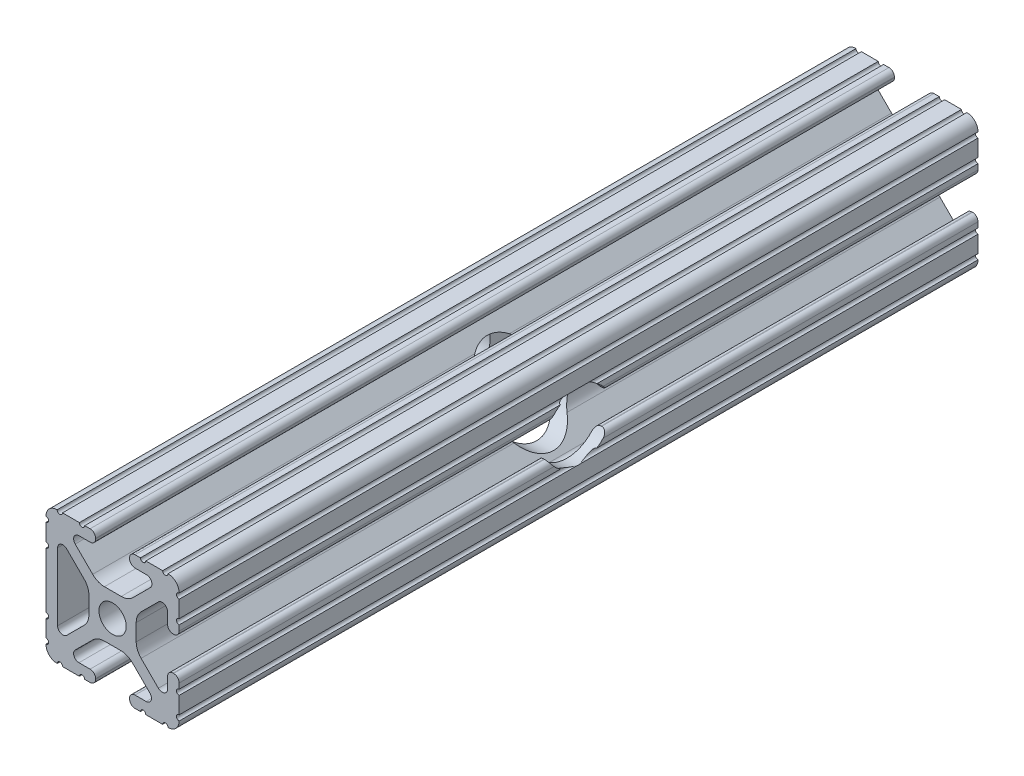
from build123d import *

# Parameters (mm, degrees)
SKETCH1_R           = 2.6035
BOSS_EXTRUDE1_DEPTH = 152.4
SKETCH2_R           = 6.35
CUT_EXTRUDE1_DEPTH  = 26.4


with BuildPart() as part:
    # Sketch1 → Boss-Extrude1 (new body)
    with BuildSketch(Plane(origin=(0, 0, -152.4), x_dir=(-1, 0, 0), z_dir=(0, 0, -1))):
        with BuildLine():
            Line((6.416409763, -10.4902), (4.28752, -10.4902))
            ThreePointArc((4.28752, -10.4902), (3.545750844, -10.797450844), (3.2385, -11.53922))
            Line((3.2385, -11.53922), (3.2385, -11.65098))
            ThreePointArc((3.2385, -11.65098), (3.545750844, -12.392749156), (4.28752, -12.7))
            Line((4.28752, -12.7), (5.3170836, -12.7))
            ThreePointArc((5.3170836, -12.7), (5.8250836, -12.192), (6.3330836, -12.7))
            Line((6.3330836, -12.7), (9.5504, -12.7))
            ThreePointArc((9.5504, -12.7), (10.058323491, -12.192000006), (10.566399977, -12.699846982))
            ThreePointArc((10.566399977, -12.699846982), (12.082522516, -12.082522516), (12.699846982, -10.566399977))
            ThreePointArc((12.699846982, -10.566399977), (12.192000006, -10.058323491), (12.7, -9.5504))
            Line((12.7, -9.5504), (12.7, -6.3330836))
            ThreePointArc((12.7, -6.3330836), (12.192, -5.8250836), (12.7, -5.3170836))
            Line((12.7, -5.3170836), (12.7, 5.3171344))
            ThreePointArc((12.7, 5.3171344), (12.192, 5.8251344), (12.7, 6.3331344))
            Line((12.7, 6.3331344), (12.7, 9.5504))
            ThreePointArc((12.7, 9.5504), (12.192000006, 10.058323491), (12.699846982, 10.566399977))
            ThreePointArc((12.699846982, 10.566399977), (12.082522516, 12.082522516), (10.566399977, 12.699846982))
            ThreePointArc((10.566399977, 12.699846982), (10.058323491, 12.192000006), (9.5504, 12.7))
            Line((9.5504, 12.7), (6.3331344, 12.7))
            ThreePointArc((6.3331344, 12.7), (5.8251344, 12.192), (5.3171344, 12.7))
            Line((5.3171344, 12.7), (4.2874692, 12.7))
            ThreePointArc((4.2874692, 12.7), (3.545700044, 12.392749156), (3.2384492, 11.65098))
            Line((3.2384492, 11.65098), (3.2384492, 11.53922))
            ThreePointArc((3.2384492, 11.53922), (3.545700044, 10.797450844), (4.2874692, 10.4902))
            Line((4.2874692, 10.4902), (6.416384363, 10.4902))
            ThreePointArc((6.416384363, 10.4902), (7.355223148, 9.862578342), (7.134149423, 8.755124678))
            Line((7.134149423, 8.755124678), (3.796632915, 5.423689619))
            ThreePointArc((3.796632915, 5.423689619), (2.767299421, 4.736928798), (1.553617102, 4.4958))
            Line((1.553617102, 4.4958), (-1.657299581, 4.4958))
            ThreePointArc((-1.657299581, 4.4958), (-2.8709819, 4.736928798), (-3.900315394, 5.423689619))
            Line((-3.900315394, 5.423689619), (-7.207191475, 8.724540082))
            ThreePointArc((-7.207191475, 8.724540082), (-7.43216212, 9.851515102), (-6.476774195, 10.4902))
            Line((-6.476774195, 10.4902), (-4.2874692, 10.4902))
            ThreePointArc((-4.2874692, 10.4902), (-3.545700044, 10.797450844), (-3.2384492, 11.53922))
            Line((-3.2384492, 11.53922), (-3.2384492, 11.65098))
            ThreePointArc((-3.2384492, 11.65098), (-3.545700044, 12.392749156), (-4.2874692, 12.7))
            Line((-4.2874692, 12.7), (-5.3170836, 12.7))
            ThreePointArc((-5.3170836, 12.7), (-5.8250836, 12.192), (-6.3330836, 12.7))
            Line((-6.3330836, 12.7), (-9.5504, 12.7))
            ThreePointArc((-9.5504, 12.7), (-10.058323491, 12.192000006), (-10.566399977, 12.699846982))
            ThreePointArc((-10.566399977, 12.699846982), (-12.082522516, 12.082522516), (-12.699846982, 10.566399977))
            ThreePointArc((-12.699846982, 10.566399977), (-12.192000006, 10.058323491), (-12.7, 9.5504))
            Line((-12.7, 9.5504), (-12.7, 6.3331344))
            ThreePointArc((-12.7, 6.3331344), (-12.192, 5.8251344), (-12.7, 5.3171344))
            Line((-12.7, 5.3171344), (-12.7, 4.287470133))
            ThreePointArc((-12.7, 4.287470133), (-12.392749156, 3.545700977), (-11.65098, 3.238450133))
            Line((-11.65098, 3.238450133), (-11.53922, 3.238450133))
            ThreePointArc((-11.53922, 3.238450133), (-10.797450844, 3.545700977), (-10.4902, 4.287470133))
            Line((-10.4902, 4.287470133), (-10.4902, 6.402089023))
            ThreePointArc((-10.4902, 6.402089023), (-9.856394933, 7.351113629), (-8.736962546, 7.129240479))
            Line((-8.736962546, 7.129240479), (-5.440484187, 3.838768792))
            ThreePointArc((-5.440484187, 3.838768792), (-4.75073678, 2.808015636), (-4.5085, 1.591658411))
            Line((-4.5085, 1.591658411), (-4.5085, -1.591658411))
            ThreePointArc((-4.5085, -1.591658411), (-4.75073678, -2.808015636), (-5.440484187, -3.838768792))
            Line((-5.440484187, -3.838768792), (-8.736962546, -7.129240479))
            ThreePointArc((-8.736962546, -7.129240479), (-9.856394933, -7.351113629), (-10.4902, -6.402089023))
            Line((-10.4902, -6.402089023), (-10.4902, -4.287470133))
            ThreePointArc((-10.4902, -4.287470133), (-10.797450844, -3.545700977), (-11.53922, -3.238450133))
            Line((-11.53922, -3.238450133), (-11.65098, -3.238450133))
            ThreePointArc((-11.65098, -3.238450133), (-12.392749156, -3.545700977), (-12.7, -4.287470133))
            Line((-12.7, -4.287470133), (-12.7, -5.3170836))
            ThreePointArc((-12.7, -5.3170836), (-12.192, -5.8250836), (-12.7, -6.3330836))
            Line((-12.7, -6.3330836), (-12.7, -9.5504))
            ThreePointArc((-12.7, -9.5504), (-12.192000006, -10.058323491), (-12.699846982, -10.566399977))
            ThreePointArc((-12.699846982, -10.566399977), (-12.082522516, -12.082522516), (-10.566399977, -12.699846982))
            ThreePointArc((-10.566399977, -12.699846982), (-10.058323491, -12.192000006), (-9.5504, -12.7))
            Line((-9.5504, -12.7), (-6.3331344, -12.7))
            ThreePointArc((-6.3331344, -12.7), (-5.8251344, -12.192), (-5.3171344, -12.7))
            Line((-5.3171344, -12.7), (-4.28752, -12.7))
            ThreePointArc((-4.28752, -12.7), (-3.545750844, -12.392749156), (-3.2385, -11.65098))
            Line((-3.2385, -11.65098), (-3.2385, -11.53922))
            ThreePointArc((-3.2385, -11.53922), (-3.545750844, -10.797450844), (-4.28752, -10.4902))
            Line((-4.28752, -10.4902), (-6.40834956, -10.4902))
            ThreePointArc((-6.40834956, -10.4902), (-7.350269456, -9.860518594), (-7.128470204, -8.749430454))
            Line((-7.128470204, -8.749430454), (-3.796658315, -5.423689619))
            ThreePointArc((-3.796658315, -5.423689619), (-2.767324821, -4.736928798), (-1.553642502, -4.4958))
            Line((-1.553642502, -4.4958), (1.553642502, -4.4958))
            ThreePointArc((1.553642502, -4.4958), (2.767324821, -4.736928798), (3.796658315, -5.423689619))
            Line((3.796658315, -5.423689619), (7.134174823, -8.755124678))
            ThreePointArc((7.134174823, -8.755124678), (7.355248548, -9.862578342), (6.416409763, -10.4902))
        make_face()
        Circle(SKETCH1_R, mode=Mode.SUBTRACT)
        with BuildLine():
            Line((10.4902, 6.446436794), (10.4902, -6.425372487))
            ThreePointArc((10.4902, -6.425372487), (9.862352148, -7.36547709), (8.753441447, -7.145689354))
            Line((8.753441447, -7.145689354), (5.440484187, -3.838768792))
            ThreePointArc((5.440484187, -3.838768792), (4.75073678, -2.808015636), (4.5085, -1.591658411))
            Line((4.5085, -1.591658411), (4.5085, 1.591658411))
            ThreePointArc((4.5085, 1.591658411), (4.75073678, 2.808015636), (5.440484187, 3.838768792))
            Line((5.440484187, 3.838768792), (8.768349738, 7.160570479))
            ThreePointArc((8.768349738, 7.160570479), (9.867741577, 7.378471563), (10.4902, 6.446436794))
        make_face(mode=Mode.SUBTRACT)
    extrude(amount=-BOSS_EXTRUDE1_DEPTH)

    # Sketch2 → Cut-Extrude1 (cut, through all)
    with BuildSketch(Plane.ZY.offset(12.7)):
        with Locations((-76.2, 0)):
            Circle(SKETCH2_R)
    extrude(amount=-CUT_EXTRUDE1_DEPTH, mode=Mode.SUBTRACT)


solid = part.part
